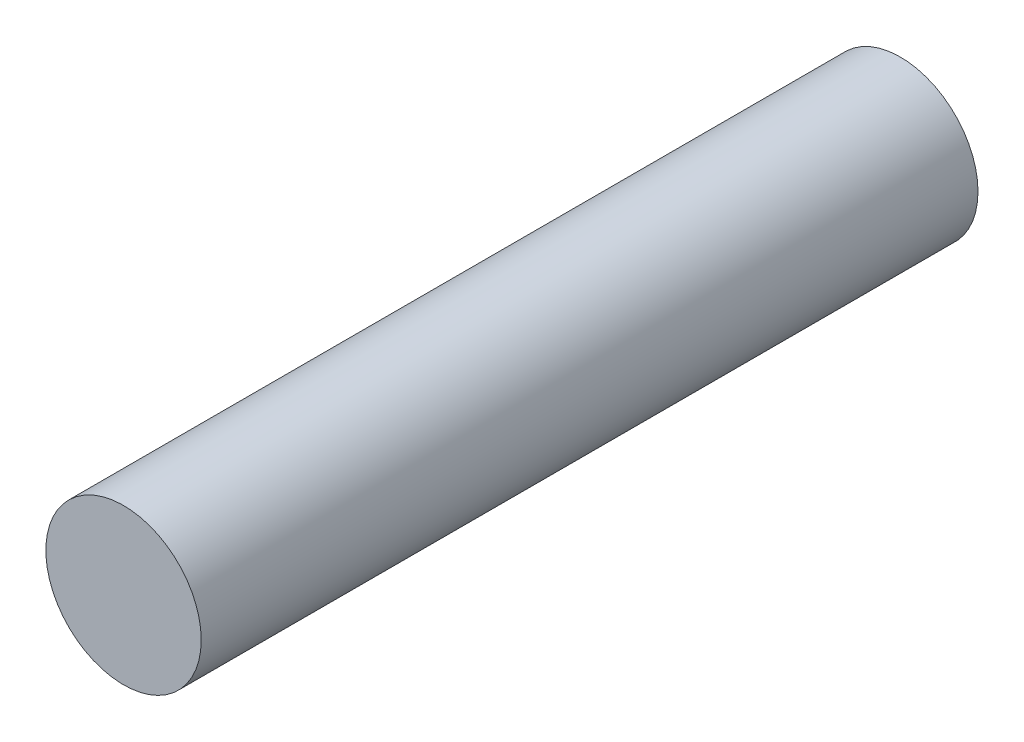
from build123d import *

# Parameters (mm, degrees)
SKETCH1_R           = 3
BOSS_EXTRUDE1_DEPTH = 30


with BuildPart() as part:
    # Sketch1 → Boss-Extrude1 (new body)
    with BuildSketch(Plane.XY):
        Circle(SKETCH1_R)
    extrude(amount=BOSS_EXTRUDE1_DEPTH)


solid = part.part
